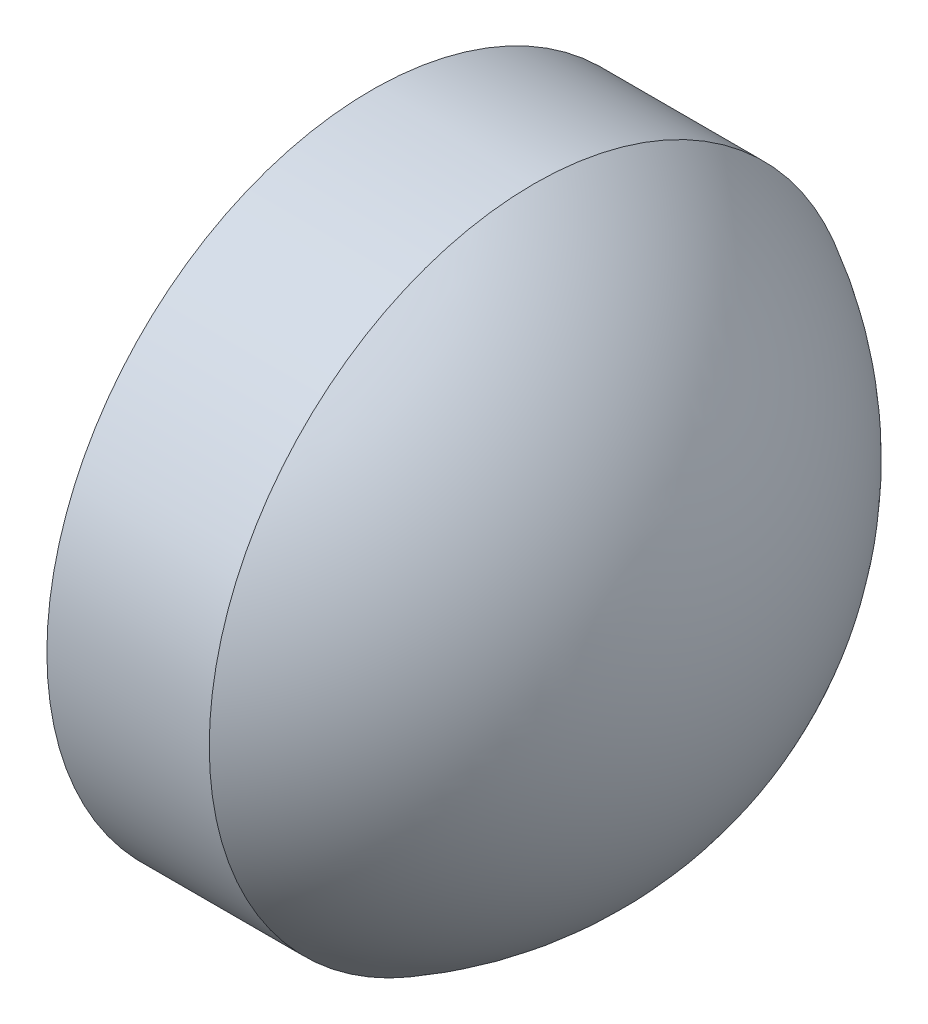
from build123d import *


with BuildPart() as part:
    # 草图1 → 旋转1 (revolve)
    with BuildSketch(Plane.XY):
        with BuildLine():
            Line((360.29253147, 32.401442128), (360.29253147, 34.401442128))
            Line((360.29253147, 34.401442128), (361.29253147, 34.401442128))
            ThreePointArc((361.29253147, 34.401442128), (362.169515435, 33.567632507), (362.49253147, 32.401442128))
            Line((362.49253147, 32.401442128), (360.29253147, 32.401442128))
        make_face()
    revolve(axis=Axis((359.864424776, 32.401442128, 0), (1, 0, 0)))


solid = part.part
